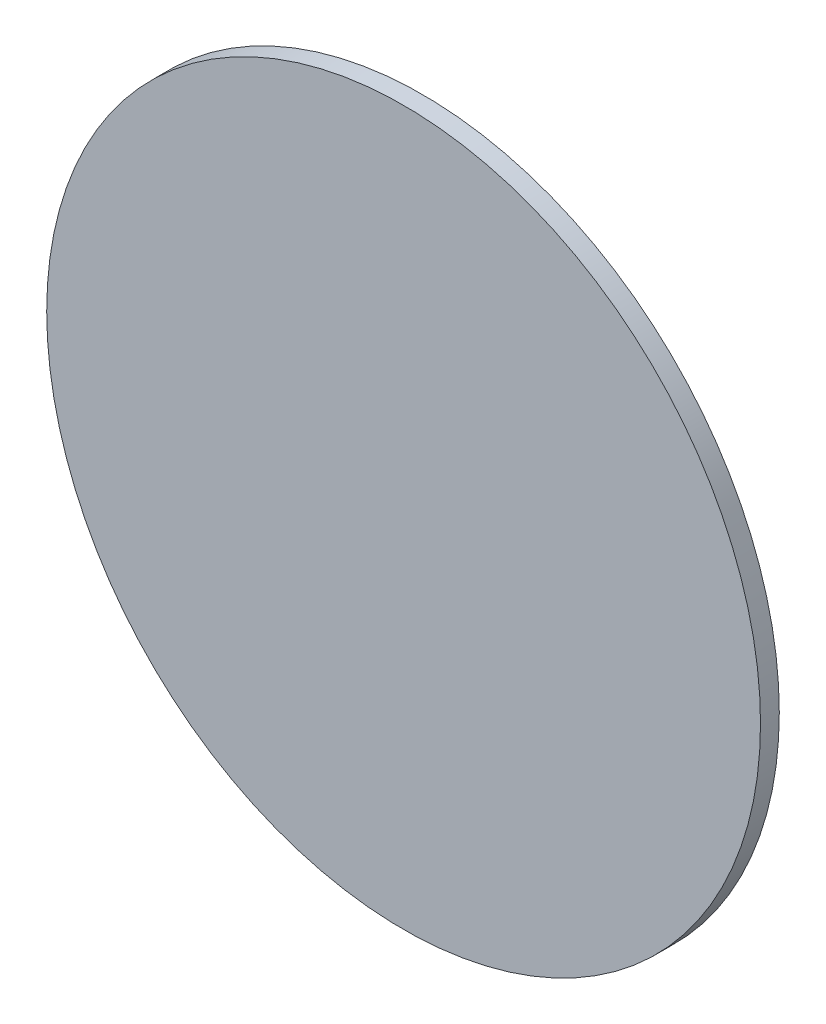
from build123d import *

# Parameters (mm, degrees)
CROQUIS1_R              = 7.6
SALIENTE_EXTRUIR1_DEPTH = 0.4


with BuildPart() as part:
    # Croquis1 → Saliente-Extruir1 (new body)
    with BuildSketch(Plane.XY):
        Circle(CROQUIS1_R)
    extrude(amount=SALIENTE_EXTRUIR1_DEPTH)


solid = part.part
